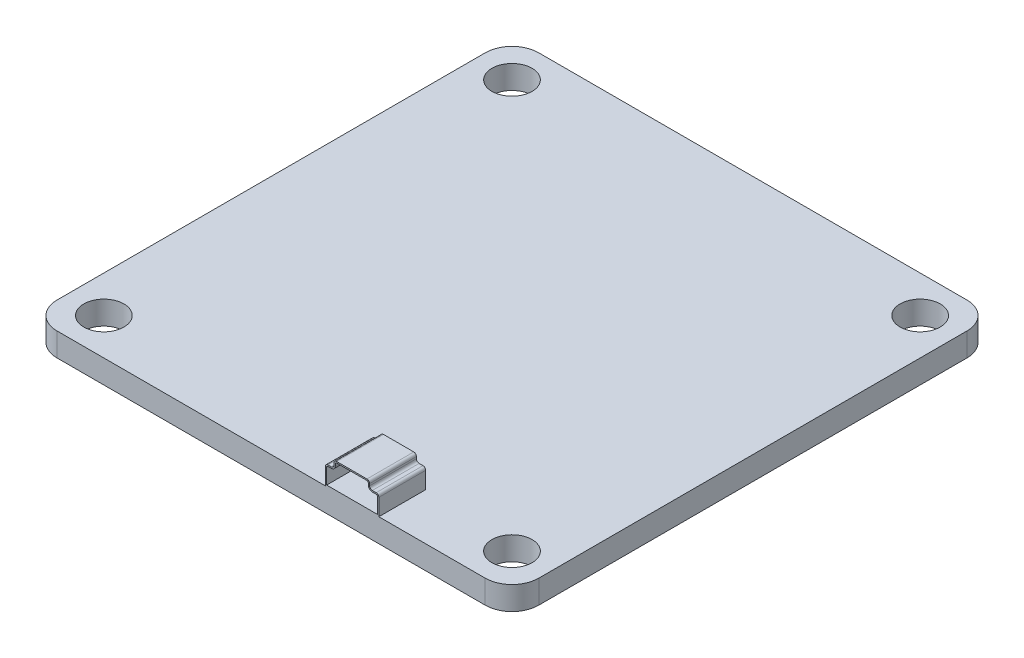
from build123d import *

# Parameters (mm, degrees)
SKETCH3_R           = 1.5
BOSS_EXTRUDE1_DEPTH = 1.75
BOSS_EXTRUDE2_DEPTH = 3
BOSS_EXTRUDE3_DEPTH = 0.5
SKETCH7_R           = 0.25
CUT_EXTRUDE1_DEPTH  = 0.5


with BuildPart() as part:
    # Sketch3 → Boss-Extrude1 (new body)
    with BuildSketch(Plane(origin=(0, 0, 0), x_dir=(1, 0, 0), z_dir=(0, 1, 0))):
        with BuildLine():
            Line((-16, 18), (16, 18))
            ThreePointArc((16, 18), (17.414213562, 17.414213562), (18, 16))
            Line((18, 16), (18, -16))
            ThreePointArc((18, -16), (17.414213562, -17.414213562), (16, -18))
            Line((16, -18), (-16, -18))
            ThreePointArc((-16, -18), (-17.414213562, -17.414213562), (-18, -16))
            Line((-18, -16), (-18, 16))
            ThreePointArc((-18, 16), (-17.414213562, 17.414213562), (-16, 18))
        make_face()
        with Locations((-15.25, 15.25)):
            Circle(SKETCH3_R, mode=Mode.SUBTRACT)
        with Locations((15.25, 15.25)):
            Circle(SKETCH3_R, mode=Mode.SUBTRACT)
        with Locations((15.25, -15.25)):
            Circle(SKETCH3_R, mode=Mode.SUBTRACT)
        with Locations((-15.25, -15.25)):
            Circle(SKETCH3_R, mode=Mode.SUBTRACT)
    extrude(amount=BOSS_EXTRUDE1_DEPTH)

    # Sketch5 → Boss-Extrude2 (add)
    with BuildSketch(Plane.XY.offset(18)):
        with BuildLine():
            Line((4.049502187, 1.75), (8.049502187, 1.75))
            Line((8.049502187, 1.75), (8.049502187, 3.006518046))
            ThreePointArc((8.049502187, 3.006518046), (7.990923543, 3.147939402), (7.849502187, 3.206518046))
            Line((7.849502187, 3.206518046), (7.559209809, 3.206518046))
            ThreePointArc((7.559209809, 3.206518046), (7.417788453, 3.26509669), (7.359209809, 3.406518046))
            Line((7.359209809, 3.406518046), (7.359209809, 3.55))
            ThreePointArc((7.359209809, 3.55), (7.300631165, 3.691421356), (7.159209809, 3.75))
            Line((7.159209809, 3.75), (4.896173717, 3.75))
            ThreePointArc((4.896173717, 3.75), (4.754752361, 3.691421356), (4.696173717, 3.55))
            Line((4.696173717, 3.55), (4.696173717, 3.406518046))
            ThreePointArc((4.696173717, 3.406518046), (4.637595073, 3.26509669), (4.496173717, 3.206518046))
            Line((4.496173717, 3.206518046), (4.249502187, 3.206518046))
            ThreePointArc((4.249502187, 3.206518046), (4.10808083, 3.147939402), (4.049502187, 3.006518046))
            Line((4.049502187, 3.006518046), (4.049502187, 1.75))
        make_face()
        with BuildLine():
            Line((4.896173717, 3.65), (7.159209809, 3.65))
            ThreePointArc((7.159209809, 3.65), (7.229920487, 3.620710678), (7.259209809, 3.55))
            Line((7.259209809, 3.55), (7.259209809, 3.406518046))
            ThreePointArc((7.259209809, 3.406518046), (7.347077775, 3.194386012), (7.559209809, 3.106518046))
            Line((7.559209809, 3.106518046), (7.849502187, 3.106518046))
            ThreePointArc((7.849502187, 3.106518046), (7.920212865, 3.077228724), (7.949502187, 3.006518046))
            Line((7.949502187, 3.006518046), (7.949502187, 1.85))
            Line((7.949502187, 1.85), (4.149502187, 1.85))
            Line((4.149502187, 1.85), (4.149502187, 3.006518046))
            ThreePointArc((4.149502187, 3.006518046), (4.178791509, 3.077228724), (4.249502187, 3.106518046))
            Line((4.249502187, 3.106518046), (4.496173717, 3.106518046))
            ThreePointArc((4.496173717, 3.106518046), (4.708305751, 3.194386012), (4.796173717, 3.406518046))
            Line((4.796173717, 3.406518046), (4.796173717, 3.55))
            ThreePointArc((4.796173717, 3.55), (4.825463039, 3.620710678), (4.896173717, 3.65))
        make_face(mode=Mode.SUBTRACT)
    extrude(amount=-BOSS_EXTRUDE2_DEPTH)

    # Sketch6 → Boss-Extrude3 (add)
    with BuildSketch(Plane(origin=(0, 0, 15), x_dir=(-1, 0, 0), z_dir=(0, 0, -1))):
        with BuildLine():
            Line((-4.049502187, 1.75), (-4.049502187, 3.006518046))
            ThreePointArc((-4.049502187, 3.006518046), (-4.10808083, 3.147939402), (-4.249502187, 3.206518046))
            Line((-4.249502187, 3.206518046), (-4.496173717, 3.206518046))
            ThreePointArc((-4.496173717, 3.206518046), (-4.637595073, 3.26509669), (-4.696173717, 3.406518046))
            Line((-4.696173717, 3.406518046), (-4.696173717, 3.55))
            ThreePointArc((-4.696173717, 3.55), (-4.754752361, 3.691421356), (-4.896173717, 3.75))
            Line((-4.896173717, 3.75), (-7.159209809, 3.75))
            ThreePointArc((-7.159209809, 3.75), (-7.300631165, 3.691421356), (-7.359209809, 3.55))
            Line((-7.359209809, 3.55), (-7.359209809, 3.406518046))
            ThreePointArc((-7.359209809, 3.406518046), (-7.417788453, 3.26509669), (-7.559209809, 3.206518046))
            Line((-7.559209809, 3.206518046), (-7.849502187, 3.206518046))
            ThreePointArc((-7.849502187, 3.206518046), (-7.990923543, 3.147939402), (-8.049502187, 3.006518046))
            Line((-8.049502187, 3.006518046), (-8.049502187, 1.75))
            Line((-8.049502187, 1.75), (-4.049502187, 1.75))
        make_face()
    extrude(amount=BOSS_EXTRUDE3_DEPTH)

    # Sketch7 → Cut-Extrude1 (cut)
    with BuildSketch(Plane(origin=(0, 0, 14.5), x_dir=(-1, 0, 0), z_dir=(0, 0, -1))):
        with Locations((-6.97797188, 2.378259023)):
            Circle(SKETCH7_R)
        with Locations((-6.17797188, 2.378259023)):
            Circle(SKETCH7_R)
        with Locations((-5.37797188, 2.378259023)):
            Circle(SKETCH7_R)
    extrude(amount=-CUT_EXTRUDE1_DEPTH, mode=Mode.SUBTRACT)


solid = part.part
